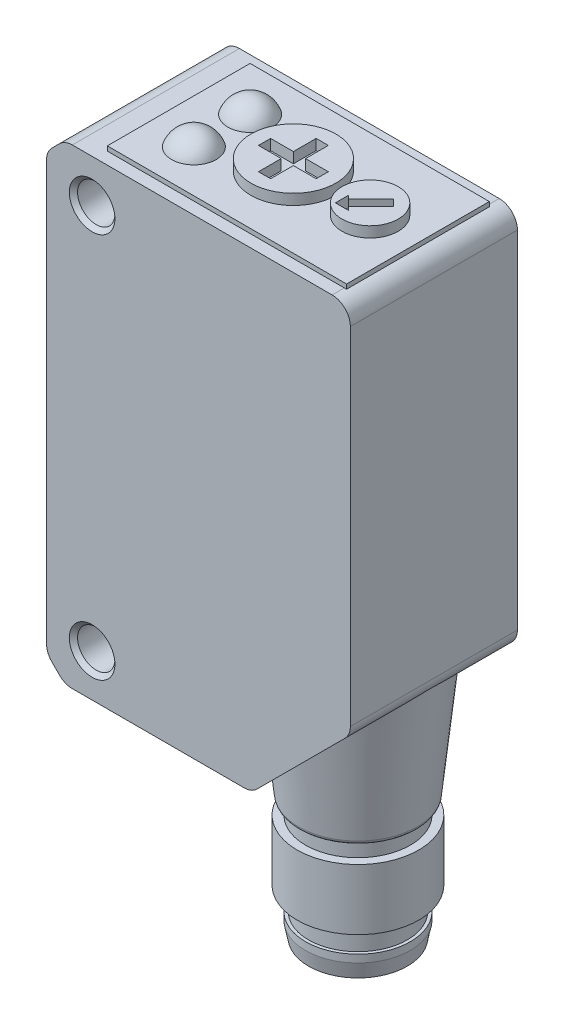
from build123d import *
from build123d.topology import SkipClean

# Parameters (mm, degrees)
BOSS_EXTRUDE1_DEPTH = 11
SKETCH3_R           = 2.9
SKETCH3_R_2         = 0.5
CUT_EXTRUDE1_DEPTH  = 4
SKETCH4_W           = 15.75
SKETCH4_H           = 9.4
BOSS_EXTRUDE2_DEPTH = 1
SKETCH5_W           = 15.75
SKETCH5_H           = 9.4
SKETCH5_R           = 1.85
SKETCH5_R_2         = 2.8
CUT_EXTRUDE2_DEPTH  = 1
SKETCH6_W           = 15.75
SKETCH6_H           = 9.4
BOSS_EXTRUDE3_DEPTH = 0.3
CUT_EXTRUDE3_DEPTH  = 0.2
CUT_EXTRUDE4_DEPTH  = 0.1


with BuildPart() as part:
    # Sketch1 → Boss-Extrude1 (new body)
    with BuildSketch(Plane.XY):
        with BuildLine():
            Line((-3, 26.502943725), (-3, -1.102943725))
            ThreePointArc((-3, -1.102943725), (-2.908655439, -1.562163844), (-2.648528137, -1.951471863))
            Line((-2.648528137, -1.951471863), (-2.151471863, -2.448528137))
            ThreePointArc((-2.151471863, -2.448528137), (-1.762163844, -2.708655439), (-1.302943725, -2.8))
            Line((-1.302943725, -2.8), (10.002943725, -2.8))
            ThreePointArc((10.002943725, -2.8), (10.462163844, -2.708655439), (10.851471863, -2.448528137))
            Line((10.851471863, -2.448528137), (16.648528137, 3.348528137))
            ThreePointArc((16.648528137, 3.348528137), (16.908655439, 3.737836156), (17, 4.197056275))
            Line((17, 4.197056275), (17, 27))
            ThreePointArc((17, 27), (16.648528137, 27.848528137), (15.8, 28.2))
            Line((15.8, 28.2), (-1.302943725, 28.2))
            ThreePointArc((-1.302943725, 28.2), (-1.762163844, 28.108655439), (-2.151471863, 27.848528137))
            Line((-2.151471863, 27.848528137), (-2.648528137, 27.351471863))
            ThreePointArc((-2.648528137, 27.351471863), (-2.908655439, 26.962163844), (-3, 26.502943725))
        make_face()
    extrude(amount=-BOSS_EXTRUDE1_DEPTH)

    # Sketch2 → Revolve1 (revolve)
    with BuildSketch(Plane.XY.offset(-5.5), mode=Mode.PRIVATE) as revolve1_sk:
        with BuildLine():
            Line((12, 4.7), (16.899094141, 4.7))
            Line((16.899094141, 4.7), (15.897307991, -4.831358539))
            ThreePointArc((15.897307991, -4.831358539), (15.799690604, -5.022943448), (15.598951422, -5.1))
            Line((15.598951422, -5.1), (15.45, -5.1))
            Line((15.45, -5.1), (15.45, -6.1))
            Line((15.45, -6.1), (16, -6.1))
            Line((16, -6.1), (16, -10.1))
            Line((16, -10.1), (15.25, -10.1))
            Line((15.25, -10.1), (15.25, -11.6))
            Line((15.25, -11.6), (15.45, -11.6))
            Line((15.45, -11.6), (15.45, -12.1))
            Line((15.45, -12.1), (15.25, -13.1))
            Line((15.25, -13.1), (12, -13.1))
            Line((12, -13.1), (12, 4.7))
        make_face()
    revolve(revolve1_sk.sketch.rotate(Axis((12, -13.1, -5.5), (0, 1, 0)), 270), axis=Axis((12, -13.1, -5.5), (0, 1, 0)))

    # Sketch3 → Cut-Extrude1 (cut)
    with BuildSketch(Plane(origin=(0, -9.3, 0), x_dir=(1, 0, 0), z_dir=(0, 1, 0))):
        with Locations(Location((12, 5.5, 0), (0, 0, 270))):
            Circle(SKETCH3_R)
        with Locations(Location((13.41577974, 4.471375808, 0), (0, 0, 270))):
            Circle(SKETCH3_R_2, mode=Mode.SUBTRACT)
        with Locations(Location((13.41577974, 6.528624192, 0), (0, 0, 270))):
            Circle(SKETCH3_R_2, mode=Mode.SUBTRACT)
        with Locations(Location((11.45922026, 3.835651096, 0), (0, 0, 270))):
            Circle(SKETCH3_R_2, mode=Mode.SUBTRACT)
        with Locations(Location((11.45922026, 7.164348904, 0), (0, 0, 270))):
            Circle(SKETCH3_R_2, mode=Mode.SUBTRACT)
    extrude(amount=-CUT_EXTRUDE1_DEPTH, mode=Mode.SUBTRACT)

    # Sketch4 → Boss-Extrude2 (add)
    with BuildSketch(Plane(origin=(0, 28.2, 0), x_dir=(1, 0, 0), z_dir=(0, 1, 0))):
        with Locations((8.075, 5.5)):
            Rectangle(SKETCH4_W, SKETCH4_H)
        Polygon((11.656497116, 4.356497116), (12.529289322, 4.356497116), (12.305025253, 4.580761184), (13.789949494, 6.065685425), (13.365685425, 6.489949494), (11.880761184, 5.005025253), (11.656497116, 5.229289322), align=None, mode=Mode.SUBTRACT)
        Polygon((5.85, 5.9), (5.85, 5.1), (7.35, 5.1), (7.35, 3.6), (8.15, 3.6), (8.15, 5.1), (9.65, 5.1), (9.65, 5.9), (8.15, 5.9), (8.15, 7.4), (7.35, 7.4), (7.35, 5.9), align=None, mode=Mode.SUBTRACT)
    extrude(amount=BOSS_EXTRUDE2_DEPTH)

    # Sketch5 → Cut-Extrude2 (cut)
    with BuildSketch(Plane(origin=(0, 28.2, 0), x_dir=(1, 0, 0), z_dir=(0, 1, 0))):
        with Locations((8.075, 5.5)):
            Rectangle(SKETCH5_W, SKETCH5_H)
        with Locations(Location((12.8, 5.5, 0), (0, 0, 270))):
            Circle(SKETCH5_R, mode=Mode.SUBTRACT)
        with Locations(Location((7.75, 5.5, 0), (0, 0, 270))):
            Circle(SKETCH5_R_2, mode=Mode.SUBTRACT)
    extrude(amount=CUT_EXTRUDE2_DEPTH, mode=Mode.SUBTRACT)

    # Sketch6 → Boss-Extrude3 (add)
    with BuildSketch(Plane(origin=(0, 28.2, 0), x_dir=(1, 0, 0), z_dir=(0, 1, 0))):
        with Locations((8.075, 5.5)):
            Rectangle(SKETCH6_W, SKETCH6_H)
    extrude(amount=BOSS_EXTRUDE3_DEPTH)

    # Sketch7 → Revolve2 (revolve)
    with SkipClean():  # the faces are left unmerged after this step: merging them gives an invalid solid
        with BuildSketch(Plane(origin=(3.1, 0, 0), x_dir=(0, 0, -1), z_dir=(1, 0, 0))):
            with BuildLine():
                Line((8.85, 28), (5.75, 28))
                ThreePointArc((5.75, 28), (7.3, 29.55), (8.85, 28))
            make_face()
        revolve(axis=Axis((3.1, 28, -8.85), (0, 0, 1)))

    # Sketch8 → Cut-Extrude3 (cut)
    with SkipClean():  # the faces are left unmerged after this step: merging them gives an invalid solid
        with BuildSketch(Plane(origin=(-2.8, 0, 0), x_dir=(0, 0, -1), z_dir=(1, 0, 0))):
            with BuildLine():
                Line((1.425, 19.925), (1.425, 2.675))
                ThreePointArc((1.425, 2.675), (1.659314575, 2.109314575), (2.225, 1.875))
                Line((2.225, 1.875), (8.775, 1.875))
                ThreePointArc((8.775, 1.875), (9.340685425, 2.109314575), (9.575, 2.675))
                Line((9.575, 2.675), (9.575, 19.925))
                ThreePointArc((9.575, 19.925), (9.340685425, 20.490685425), (8.775, 20.725))
                Line((8.775, 20.725), (2.225, 20.725))
                ThreePointArc((2.225, 20.725), (1.659314575, 20.490685425), (1.425, 19.925))
            make_face()
        extrude(amount=-CUT_EXTRUDE3_DEPTH, mode=Mode.SUBTRACT)

    # Sketch9 → Cut-Extrude4 (cut)
    with SkipClean():  # the faces are left unmerged after this step: merging them gives an invalid solid
        with BuildSketch(Plane.XY.offset(-11)):
            with BuildLine():
                Line((4.4, 0.2), (9.091673888, 0.2))
                ThreePointArc((9.091673888, 0.2), (9.244747261, 0.230448187), (9.3745166, 0.317157288))
                Line((9.3745166, 0.317157288), (13.882842712, 4.8254834))
                ThreePointArc((13.882842712, 4.8254834), (13.969551813, 4.955252739), (14, 5.108326112))
                Line((14, 5.108326112), (14, 24.8))
                ThreePointArc((14, 24.8), (13.882842712, 25.082842712), (13.6, 25.2))
                Line((13.6, 25.2), (4.4, 25.2))
                ThreePointArc((4.4, 25.2), (4.117157288, 25.082842712), (4, 24.8))
                Line((4, 24.8), (4, 0.6))
                ThreePointArc((4, 0.6), (4.117157288, 0.317157288), (4.4, 0.2))
            make_face()
        extrude(amount=CUT_EXTRUDE4_DEPTH, mode=Mode.SUBTRACT)

    # Sketch10 → Cut-Revolve1 (revolve, cut)
    with SkipClean():  # the faces are left unmerged after this step: merging them gives an invalid solid
        with BuildSketch(Plane(origin=(0, 0, 0), x_dir=(0, 0, -1), z_dir=(1, 0, 0)), mode=Mode.PRIVATE) as cut_revolve1_sk:
            Polygon((0, 0), (0, 1.5), (0.2705, 1.2295), (10.7295, 1.2295), (11, 1.5), (11, 0), align=None)
        revolve(cut_revolve1_sk.sketch.rotate(Axis((0, 0, -11), (0, 0, 1)), 270), axis=Axis((0, 0, -11), (0, 0, 1)), mode=Mode.SUBTRACT)

    # Sketch11 → Cut-Revolve2 (revolve, cut)
    with SkipClean():  # the faces are left unmerged after this step: merging them gives an invalid solid
        with BuildSketch(Plane(origin=(0, 0, 0), x_dir=(0, 0, -1), z_dir=(1, 0, 0)), mode=Mode.PRIVATE) as cut_revolve2_sk:
            Polygon((0, 25.4), (0, 26.9), (0.2705, 26.6295), (10.7295, 26.6295), (11, 26.9), (11, 25.4), align=None)
        revolve(cut_revolve2_sk.sketch.rotate(Axis((0, 25.4, -11), (0, 0, 1)), 270), axis=Axis((0, 25.4, -11), (0, 0, 1)), mode=Mode.SUBTRACT)

    # Sketch12 → Revolve3 (revolve)
    with SkipClean():  # the faces are left unmerged after this step: merging them gives an invalid solid
        with BuildSketch(Plane(origin=(3.1, 0, 0), x_dir=(0, 0, -1), z_dir=(1, 0, 0))):
            with BuildLine():
                Line((5.15, 28), (2.05, 28))
                ThreePointArc((2.05, 28), (3.6, 29.55), (5.15, 28))
            make_face()
        revolve(axis=Axis((3.1, 28, -5.15), (0, 0, 1)))


solid = part.part
